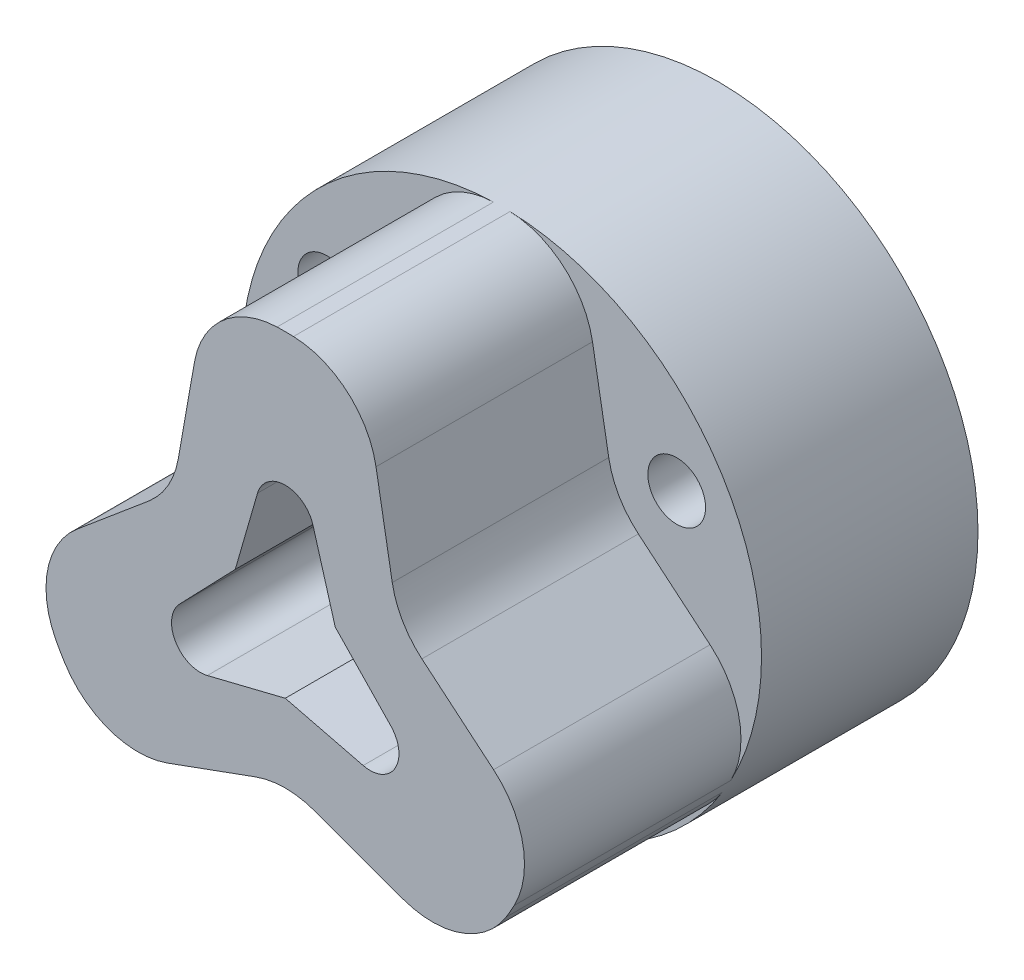
from build123d import *

# Parameters (mm, degrees)
SKETCH1_R                = 18
BOSS_EXTRUDE1_DEPTH      = 30
SKETCH2_R                = 2
CUT_EXTRUDE1_DEPTH       = 40
CUT_EXTRUDE2_DEPTH       = 15
FILLET2_R                = 6
CIRPATTERN3_COUNT        = 3
FILLET2_OF_CIRPATTERN3_R = 6
CUT_EXTRUDE3_START       = -30
CUT_EXTRUDE3_DEPTH       = 30
FILLET3_R                = 2


with BuildPart() as part:
    # Sketch1 → Boss-Extrude1 (new body)
    with BuildSketch(Plane.XY):
        Circle(SKETCH1_R)
    extrude(amount=BOSS_EXTRUDE1_DEPTH)

    # Sketch2 → Cut-Extrude1 (cut)
    with BuildSketch(Plane(origin=(0, 0, 0), x_dir=(-1, 0, 0), z_dir=(0, 0, -1))):
        with Locations((12.124355653, 7)):
            Circle(SKETCH2_R)
    cut_extrude1 = extrude(amount=-CUT_EXTRUDE1_DEPTH, mode=Mode.SUBTRACT)

    # Sketch3 → Cut-Extrude2 (cut)
    with BuildSketch(Plane.XY.offset(30)):
        Polygon((-15.686533479, 14.830127019), (-20.686533479, 6.169872981), (-17.60824379, -3.734936498), (-7.794228634, 4.5), (-5.569572007, 17.116654687), align=None)
    cut_extrude2 = extrude(amount=-CUT_EXTRUDE2_DEPTH, mode=Mode.SUBTRACT)

    # Fillet2
    fillet2_edges = [part.edges().sort_by_distance(p)[0] for p in [
        (-7.794228634, 4.5, 22.5),
        (-17.60824379, -3.734936498, 22.5),
        (-5.569572007, 17.116654687, 22.5),
    ]]
    fillet(fillet2_edges, radius=FILLET2_R)

    # CirPattern3: Cut-Extrude1, Cut-Extrude2 ×3 about axis
    cirpattern3_axis = Axis((0, 0, 0), (0, 0, 1))
    for i in range(1, CIRPATTERN3_COUNT):
        add(cut_extrude1.rotate(cirpattern3_axis, i * 360 / CIRPATTERN3_COUNT), mode=Mode.SUBTRACT)
        add(cut_extrude2.rotate(cirpattern3_axis, i * 360 / CIRPATTERN3_COUNT), mode=Mode.SUBTRACT)

    # Fillet2 of CirPattern3
    fillet2_of_cirpattern3_edges = [part.edges().sort_by_distance(p)[0] for p in [
        (0, -9, 22.5),
        (12.038671783, -13.381718189, 22.5),
        (-12.038671783, -13.381718189, 22.5),
        (7.794228634, 4.5, 22.5),
        (5.569572007, 17.116654687, 22.5),
        (17.60824379, -3.734936498, 22.5),
    ]]
    fillet(fillet2_of_cirpattern3_edges, radius=FILLET2_OF_CIRPATTERN3_R)

    # Sketch4 → Cut-Extrude3 (cut)
    with BuildSketch(Plane.XY.offset(30).offset(CUT_EXTRUDE3_START)):
        Polygon((-12.124355653, -7), (-3.464101615, 2), (0, 14), (3.464101615, 2), (12.124355653, -7), (0, -4), align=None)
    extrude(amount=CUT_EXTRUDE3_DEPTH, mode=Mode.SUBTRACT)

    # Fillet3
    fillet3_edges = [part.edges().sort_by_distance(p)[0] for p in [
        (12.124355653, -7, 15),
        (-12.124355653, -7, 15),
        (0, 14, 15),
    ]]
    fillet(fillet3_edges, radius=FILLET3_R)


solid = part.part
